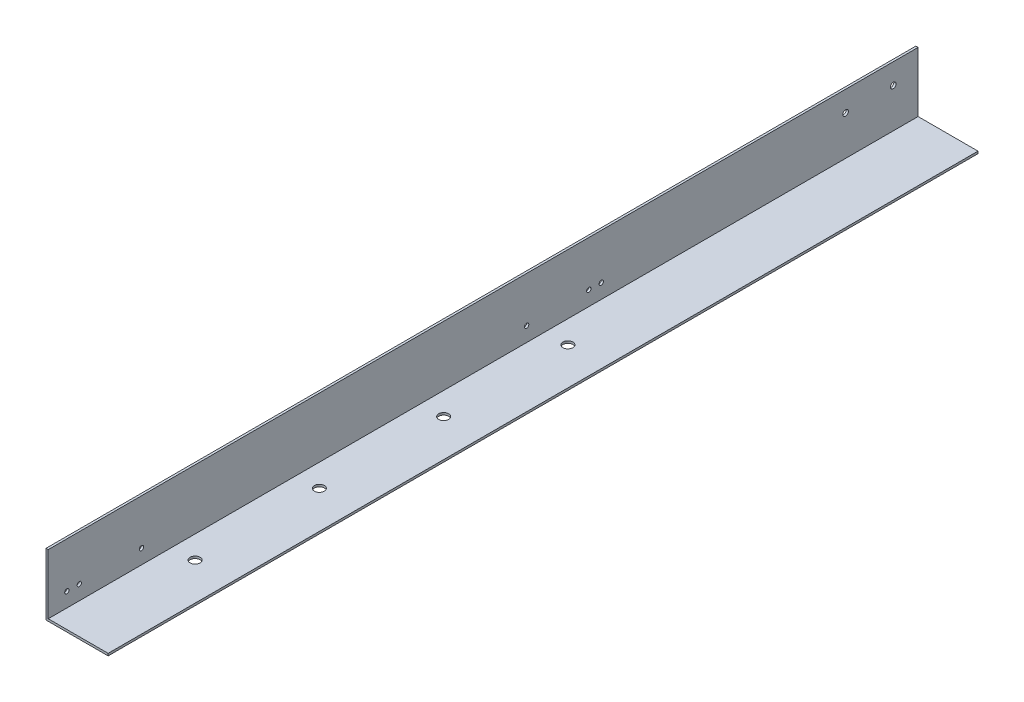
from build123d import *

# Parameters (mm, degrees)
EXTRUDE_1_DEPTH             = 700
SKETCH_2_R                  = 4
CUT_EXTRUDE_1_DEPTH         = 10
SKETCH_3_R                  = 2.25
CUT_EXTRUDE_2_DEPTH         = 51
HOLE_WIZARD_3_5_3_5_1_D     = 3.5
HOLE_WIZARD_3_5_3_5_1_DEPTH = 2
HOLE_WIZARD_3_5_3_5_1_TIP   = 1.051506083


with BuildPart() as part:
    # 草圖1 → 填料-伸長1 (new body)
    with BuildSketch(Plane.XY):
        Polygon((0, 50), (0, 0), (50, 0), (50, 1.8), (1.8, 1.8), (1.8, 50), align=None)
    extrude(amount=EXTRUDE_1_DEPTH)

    # 草圖2 → 除料-伸長1 (cut)
    with BuildSketch(Plane(origin=(0, 0, 0), x_dir=(-1, 0, 0), z_dir=(0, -1, 0))):
        with Locations((-20, -300)):
            Circle(SKETCH_2_R)
        with Locations((-20, -600)):
            Circle(SKETCH_2_R)
        with Locations((-20, -500)):
            Circle(SKETCH_2_R)
        with Locations((-20, -400)):
            Circle(SKETCH_2_R)
    extrude(amount=-CUT_EXTRUDE_1_DEPTH, mode=Mode.SUBTRACT)

    # 草圖3 → 除料-伸長2 (cut, through all)
    with BuildSketch(Plane.ZY):
        with Locations((58.34, 33.5)):
            Circle(SKETCH_3_R)
        with Locations((20, 33.5)):
            Circle(SKETCH_3_R)
    extrude(amount=-CUT_EXTRUDE_2_DEPTH, mode=Mode.SUBTRACT)

    # Ø3.5 (3.5) 直徑孔1
    with Locations(Plane.ZY):
        with Locations((685, 13.5), (675, 13.5), (625, 13.5), (255, 13.5), (265, 13.5), (315, 13.5)):
            Hole(HOLE_WIZARD_3_5_3_5_1_D / 2, depth=HOLE_WIZARD_3_5_3_5_1_DEPTH)
            with Locations((0, 0, -(HOLE_WIZARD_3_5_3_5_1_DEPTH + HOLE_WIZARD_3_5_3_5_1_TIP / 2))):  # 118° drill point
                Cone(0, HOLE_WIZARD_3_5_3_5_1_D / 2, HOLE_WIZARD_3_5_3_5_1_TIP, mode=Mode.SUBTRACT)


solid = part.part
